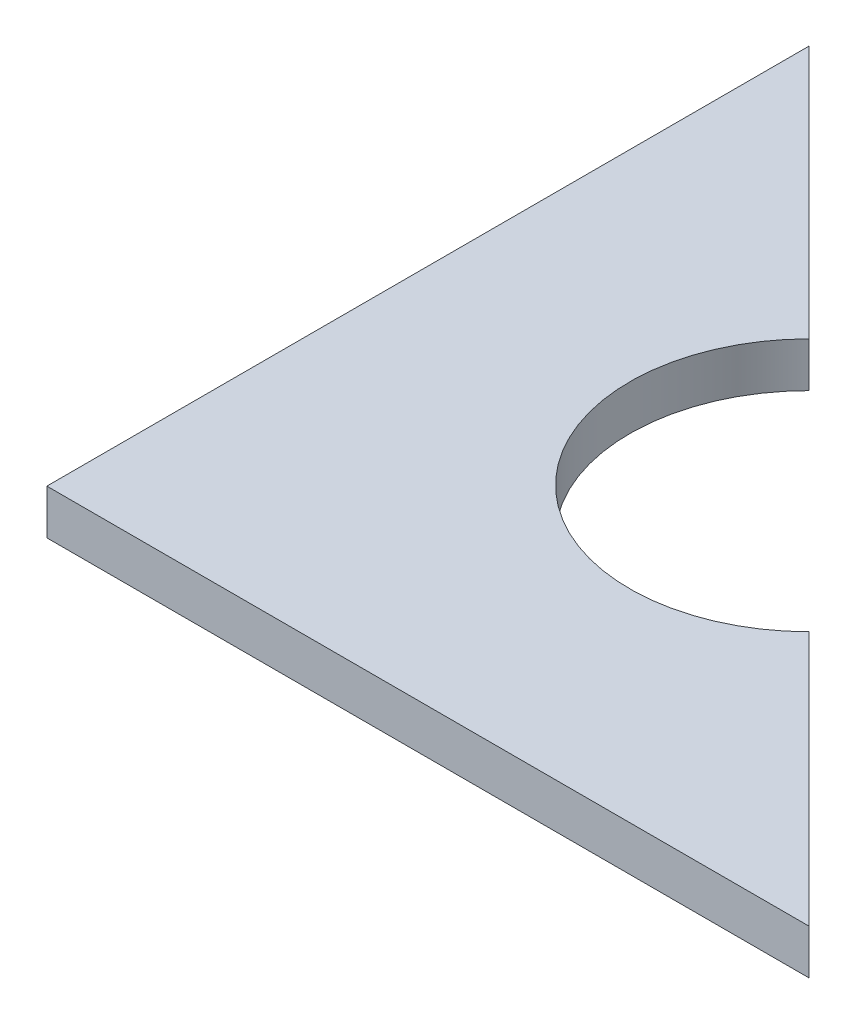
from build123d import *

# Parameters (mm, degrees)
BOSS_EXTRU_1_DEPTH = 5


with BuildPart() as part:
    # Esquisse1 → Boss.-Extru.1 (new body)
    with BuildSketch(Plane(origin=(0, 0, 0), x_dir=(1, 0, 0), z_dir=(0, 1, 0))):
        with BuildLine():
            Line((-14.220317816, 14.220317816), (-42.5, 42.5))
            Line((-42.5, 42.5), (-42.5, -42.5))
            Line((-42.5, -42.5), (42.5, -42.5))
            Line((42.5, -42.5), (14.063953431, -14.063953431))
            ThreePointArc((14.063953431, -14.063953431), (-14.220317816, -14.063953431), (-14.220317816, 14.220317816))
        make_face()
    extrude(amount=BOSS_EXTRU_1_DEPTH)


solid = part.part
